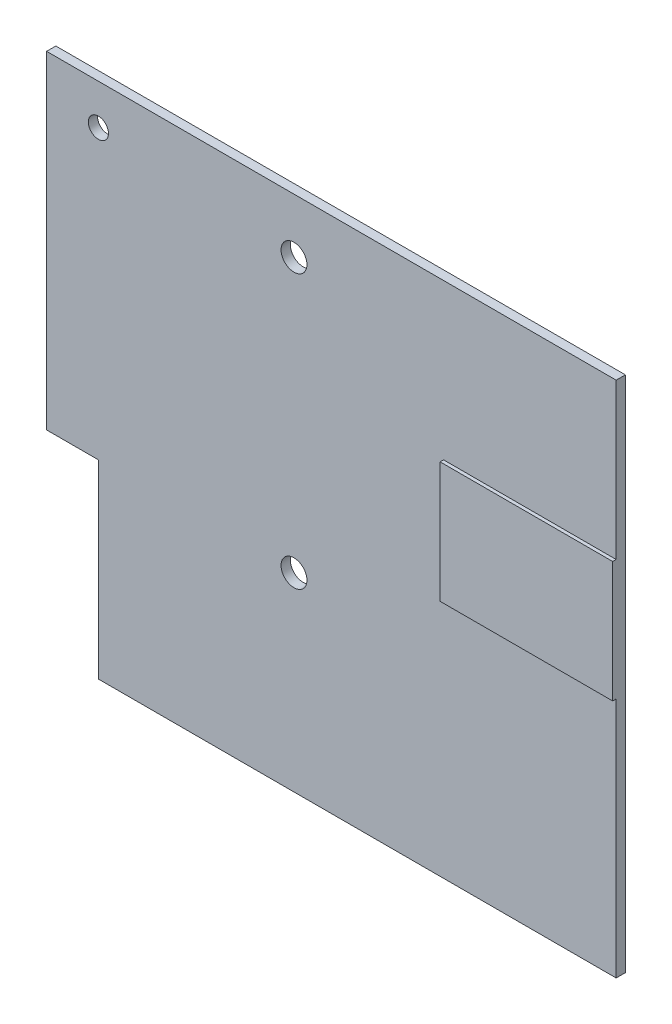
from build123d import *

# Parameters (mm, degrees)
BOARDBASE_DEPTH      = 1.6
SKETCH2_R            = 1.75
SKETCH2_R_2          = 2.25
EXISTING_HOLES_DEPTH = 2.6
SKETCH3_W            = 30
SKETCH3_H            = 21
FREE_AREA_DEPTH      = 0.6


with BuildPart() as part:
    # Sketch1 → BoardBase (new body)
    with BuildSketch(Plane.XY):
        Polygon((9, 0), (99, 0), (99, 90), (0, 90), (0, 33), (9, 33), align=None)
    extrude(amount=-BOARDBASE_DEPTH)

    # Sketch2 → Existing Holes (cut, through all)
    with BuildSketch(Plane.XY):
        with Locations((9, 83)):
            Circle(SKETCH2_R)
        with Locations((43, 80.5)):
            Circle(SKETCH2_R_2)
        with Locations((43, 33)):
            Circle(SKETCH2_R_2)
    extrude(amount=-EXISTING_HOLES_DEPTH, mode=Mode.SUBTRACT)

    # Sketch3 → 'Free' area (add)
    with BuildSketch(Plane.XY):
        with Locations((84, 52.5)):
            Rectangle(SKETCH3_W, SKETCH3_H)
    extrude(amount=FREE_AREA_DEPTH)


solid = part.part
